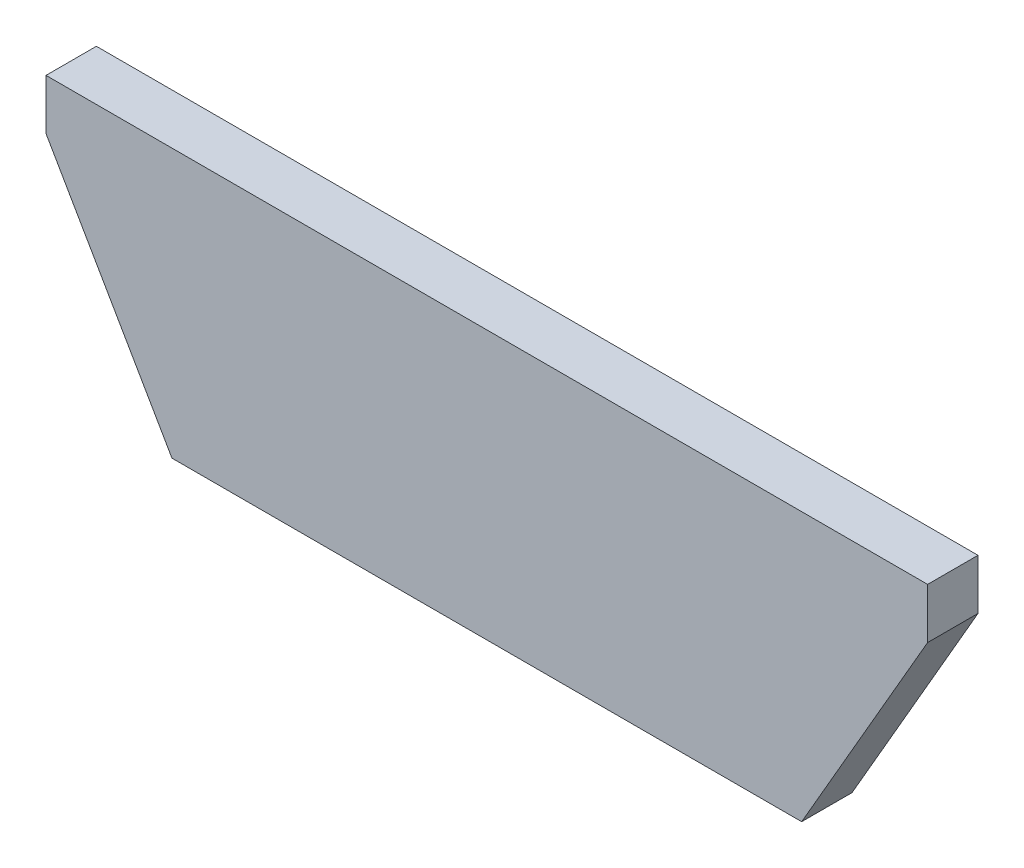
from build123d import *

# Parameters (mm, degrees)
BOSS_EXTRUDE1_DEPTH = 5.08


with BuildPart() as part:
    # Sketch1 → Boss-Extrude1 (new body)
    with BuildSketch(Plane.XY):
        Polygon((0, 0), (63.5, 0), (76.2, 21.997045256), (76.2, 27.077045256), (-12.7, 27.077045256), (-12.7, 21.997045256), align=None)
    extrude(amount=BOSS_EXTRUDE1_DEPTH)


solid = part.part
